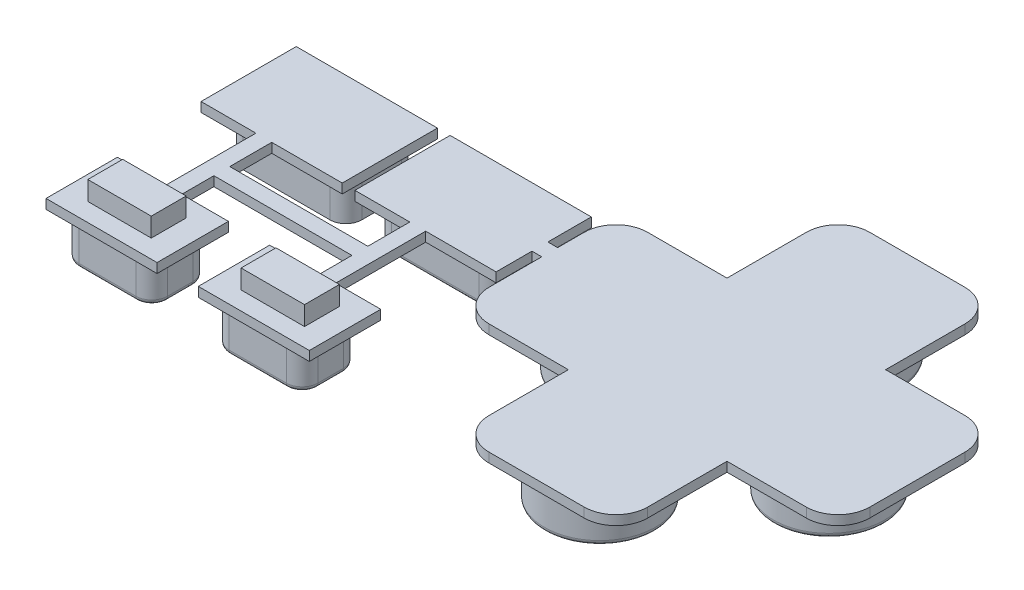
from build123d import *

# Parameters (mm, degrees)
EXTRUDE_1_DEPTH   = 0.6
SKETCH_3_W        = 8.9
SKETCH_3_H        = 6
EXTRUDE_3_DEPTH   = 0.6
EXTRUDE_3_2_DEPTH = 0.6
SKETCH_3_W_2      = 7
SKETCH_3_H_2      = 4.5
EXTRUDE_3_3_DEPTH = 0.6
EXTRUDE_3_4_DEPTH = 0.6
SKETCH_4_W        = 1
SKETCH_4_H        = 6.374610307
EXTRUDE_4_DEPTH   = 0.6
SKETCH_4_H_2      = 6.651172628
EXTRUDE_4_2_DEPTH = 0.6
SKETCH_5_W        = 8.701270278
SKETCH_5_H        = 1
SKETCH_5_W_2      = 0.617391651
EXTRUDE_5_DEPTH   = 0.6
SKETCH_6_W        = 5.6
SKETCH_6_H        = 3.6
SKETCH_6_W_2      = 7.5
SKETCH_6_H_2      = 4.5
EXTRUDE_6_DEPTH   = 2.6
FILLET_2_R        = 1
SKETCH_8_W        = 4
SKETCH_8_H        = 2.2
EXTRUDE_7_DEPTH   = 1.2
SKETCH_9_R        = 3.5
EXTRUDE_8_DEPTH   = 2.8
FILLET_3_R        = 0.3
FILLET_4_R        = 0.3


with BuildPart() as part:
    # 草图1 → 凸台-拉伸1 (new body)
    with BuildSketch(Plane(origin=(0, 0, 0), x_dir=(1, 0, 0), z_dir=(0, 1, 0))):
        with BuildLine():
            Line((-10.355628916, -1.581012653), (-15.355628916, -1.581012653))
            ThreePointArc((-15.355628916, -1.581012653), (-16.769842478, -0.995226215), (-17.355628916, 0.418987347))
            Line((-17.355628916, 0.418987347), (-17.355628916, 6.418987347))
            ThreePointArc((-17.355628916, 6.418987347), (-16.769842478, 7.83320091), (-15.355628916, 8.418987347))
            Line((-15.355628916, 8.418987347), (-10.355628916, 8.418987347))
            Line((-10.355628916, 8.418987347), (-10.355628916, 13.418987347))
            ThreePointArc((-10.355628916, 13.418987347), (-9.769842478, 14.83320091), (-8.355628916, 15.418987347))
            Line((-8.355628916, 15.418987347), (-2.355628916, 15.418987347))
            ThreePointArc((-2.355628916, 15.418987347), (-0.941415353, 14.83320091), (-0.355628916, 13.418987347))
            Line((-0.355628916, 13.418987347), (-0.355628916, 8.418987347))
            Line((-0.355628916, 8.418987347), (4.644371084, 8.418987347))
            ThreePointArc((4.644371084, 8.418987347), (6.058584647, 7.83320091), (6.644371084, 6.418987347))
            Line((6.644371084, 6.418987347), (6.644371084, 0.418987347))
            ThreePointArc((6.644371084, 0.418987347), (6.058584647, -0.995226215), (4.644371084, -1.581012653))
            Line((4.644371084, -1.581012653), (-0.355628916, -1.581012653))
            Line((-0.355628916, -1.581012653), (-0.355628916, -6.581012653))
            ThreePointArc((-0.355628916, -6.581012653), (-0.941415353, -7.995226215), (-2.355628916, -8.581012653))
            Line((-2.355628916, -8.581012653), (-8.355628916, -8.581012653))
            ThreePointArc((-8.355628916, -8.581012653), (-9.769842478, -7.995226215), (-10.355628916, -6.581012653))
            Line((-10.355628916, -6.581012653), (-10.355628916, -1.581012653))
        make_face()
    extrude(amount=EXTRUDE_1_DEPTH)



with BuildPart() as body_2:
    # 草图3 → 凸台-拉伸3 (new body)
    with BuildSketch(Plane.XZ):
        with Locations((-32.123020567, -4.482948627)):
            Rectangle(SKETCH_3_W, SKETCH_3_H)
    extrude(amount=-EXTRUDE_3_DEPTH)


with BuildPart() as body_3:
    # 草图3 → Extrude 3 2 (new body)
    with BuildSketch(Plane.XZ):
        with Locations((-22.423020567, -4.482948627)):
            Rectangle(SKETCH_3_W, SKETCH_3_H)
    extrude(amount=-EXTRUDE_3_2_DEPTH)


with BuildPart() as body_4:
    # 草图3 → Extrude 3 3 (new body)
    with BuildSketch(Plane.XZ):
        with Locations((-32.668750019, 6.445978318)):
            Rectangle(SKETCH_3_W_2, SKETCH_3_H_2)
    extrude(amount=-EXTRUDE_3_3_DEPTH)


with BuildPart() as body_5:
    # 草图3 → Extrude 3 4 (new body)
    with BuildSketch(Plane.XZ):
        with Locations((-23.068750019, 6.445978318)):
            Rectangle(SKETCH_3_W_2, SKETCH_3_H_2)
    extrude(amount=-EXTRUDE_3_4_DEPTH)


with BuildPart() as body_6:
    # 草图4 → 凸台-拉伸4 (new body)
    with BuildSketch(Plane.XZ):
        with Locations((-32.61660435, 1.531203151)):
            Rectangle(SKETCH_4_W, SKETCH_4_H)
    extrude(amount=-EXTRUDE_4_DEPTH)


with BuildPart() as body_7:
    # 草图4 → Extrude 4 2 (new body)
    with BuildSketch(Plane.XZ):
        with Locations((-22.915334072, 1.563464225)):
            Rectangle(SKETCH_4_W, SKETCH_4_H_2)
    extrude(amount=-EXTRUDE_4_2_DEPTH)


with BuildPart() as part_1:
    add(part.part)

    add(body_3.part)  # 凸台-拉伸5 merges body 3

    add(body_6.part)  # 凸台-拉伸5 merges body 6

    add(body_7.part)  # 凸台-拉伸5 merges body 7
    # 草图5 → 凸台-拉伸5 (add)
    with BuildSketch(Plane.XZ):
        with Locations((-27.765969211, 1.663532577)):
            Rectangle(SKETCH_5_W, SKETCH_5_H)
        with Locations((-17.664324742, -4.243803878)):
            Rectangle(SKETCH_5_W_2, SKETCH_5_H)
    extrude(amount=-EXTRUDE_5_DEPTH)


    add(body_2.part)  # 凸台-拉伸6 merges body 2

    add(body_4.part)  # 凸台-拉伸6 merges body 4

    add(body_5.part)  # 凸台-拉伸6 merges body 5
    # 草图6 → 凸台-拉伸6 (add)
    with BuildSketch(Plane.XZ):
        with Locations((-32.697859359, 6.501200347)):
            Rectangle(SKETCH_6_W, SKETCH_6_H)
        with Locations((-23.216713991, 6.501200347)):
            Rectangle(SKETCH_6_W, SKETCH_6_H)
        with Locations((-31.993020567, -4.532948627)):
            Rectangle(SKETCH_6_W_2, SKETCH_6_H_2)
        with Locations((-22.613020567, -4.532948627)):
            Rectangle(SKETCH_6_W_2, SKETCH_6_H_2)
    extrude(amount=EXTRUDE_6_DEPTH)

    # 圆角2
    fillet_2_edges = [part_1.edges().sort_by_distance(p)[0] for p in [
        (-35.497859359, -1.3, 8.301200347),
        (-35.497859359, -1.3, 4.701200347),
        (-29.897859359, -1.3, 4.701200347),
        (-29.897859359, -1.3, 8.301200347),
        (-26.016713991, -1.3, 8.301200347),
        (-26.016713991, -1.3, 4.701200347),
        (-20.416713991, -1.3, 4.701200347),
        (-20.416713991, -1.3, 8.301200347),
        (-26.363020567, -1.3, -2.282948627),
        (-26.363020567, -1.3, -6.782948627),
        (-18.863020567, -1.3, -6.782948627),
        (-18.863020567, -1.3, -2.282948627),
        (-35.743020567, -1.3, -2.282948627),
        (-35.743020567, -1.3, -6.782948627),
        (-28.243020567, -1.3, -6.782948627),
        (-28.243020567, -1.3, -2.282948627),
    ]]
    fillet(fillet_2_edges, radius=FILLET_2_R)

    # 草图8 → 凸台-拉伸7 (add)
    with BuildSketch(Plane(origin=(0, 0.6, 0), x_dir=(1, 0, 0), z_dir=(0, 1, 0))):
        with Locations((-32.685632336, -6.44436416)):
            Rectangle(SKETCH_8_W, SKETCH_8_H)
        with Locations((-23.023359298, -6.44436416)):
            Rectangle(SKETCH_8_W, SKETCH_8_H)
    extrude(amount=EXTRUDE_7_DEPTH)

    # 草图9 → 凸台-拉伸8 (add)
    with BuildSketch(Plane.XZ):
        with Locations(Location((-12.024365416, -3.276163463, 0), (0, 0, 270))):  # turned: the seam where the file's is
            Circle(SKETCH_9_R)
        with Locations(Location((-5.604365416, 4.343836537, 0), (0, 0, 270))):  # turned: the seam where the file's is
            Circle(SKETCH_9_R)
        with Locations(Location((-5.604365416, -11.069030807, 0), (0, 0, 270))):  # turned: the seam where the file's is
            Circle(SKETCH_9_R)
        with Locations(Location((1.225634584, -3.276163463, 0), (0, 0, 270))):  # turned: the seam where the file's is
            Circle(SKETCH_9_R)
    extrude(amount=EXTRUDE_8_DEPTH)

    # 圆角3
    fillet_3_edges = [part_1.edges().sort_by_distance(p)[0] for p in [
        (-12.024365416, -2.8, 0.223836537),
        (-5.604365416, -2.8, 7.843836537),
        (-5.604365416, -2.8, -7.569030807),
        (1.225634584, -2.8, 0.223836537),
    ]]
    fillet(fillet_3_edges, radius=FILLET_3_R)

    # 圆角4
    fillet_4_edges = [part_1.edges().sort_by_distance(p)[0] for p in [
        (-22.613020567, -2.6, -6.782948627),
        (-26.363020567, -2.6, -4.532948627),
        (-18.863020567, -2.6, -4.532948627),
        (-22.613020567, -2.6, -2.282948627),
        (-26.070127348, -2.6, -2.575841846),
        (-19.155913786, -2.6, -2.575841846),
        (-19.155913786, -2.6, -6.490055408),
        (-26.070127348, -2.6, -6.490055408),
        (-31.993020567, 0, -2.282948627),
        (-28.243020567, 0, -4.532948627),
        (-35.743020567, 0, -4.532948627),
        (-31.993020567, 0, -6.782948627),
        (-20.416713991, -2.6, 6.501200347),
        (-23.216713991, -2.6, 4.701200347),
        (-26.016713991, -2.6, 6.501200347),
        (-23.216713991, -2.6, 8.301200347),
        (-25.723820772, -2.6, 8.008307128),
        (-20.70960721, -2.6, 8.008307128),
        (-25.723820772, -2.6, 4.994093566),
        (-20.70960721, -2.6, 4.994093566),
        (-35.497859359, -2.6, 6.501200347),
        (-32.697859359, -2.6, 8.301200347),
        (-32.697859359, -2.6, 4.701200347),
        (-29.897859359, -2.6, 6.501200347),
        (-35.20496614, -2.6, 4.994093566),
        (-30.190752578, -2.6, 4.994093566),
        (-30.190752578, -2.6, 8.008307128),
        (-35.20496614, -2.6, 8.008307128),
        (-28.535913786, 0, -2.575841846),
        (-35.450127348, 0, -2.575841846),
        (-35.450127348, 0, -6.490055408),
        (-28.535913786, 0, -6.490055408),
    ]]
    fillet(fillet_4_edges, radius=FILLET_4_R)


solid = part_1.part
